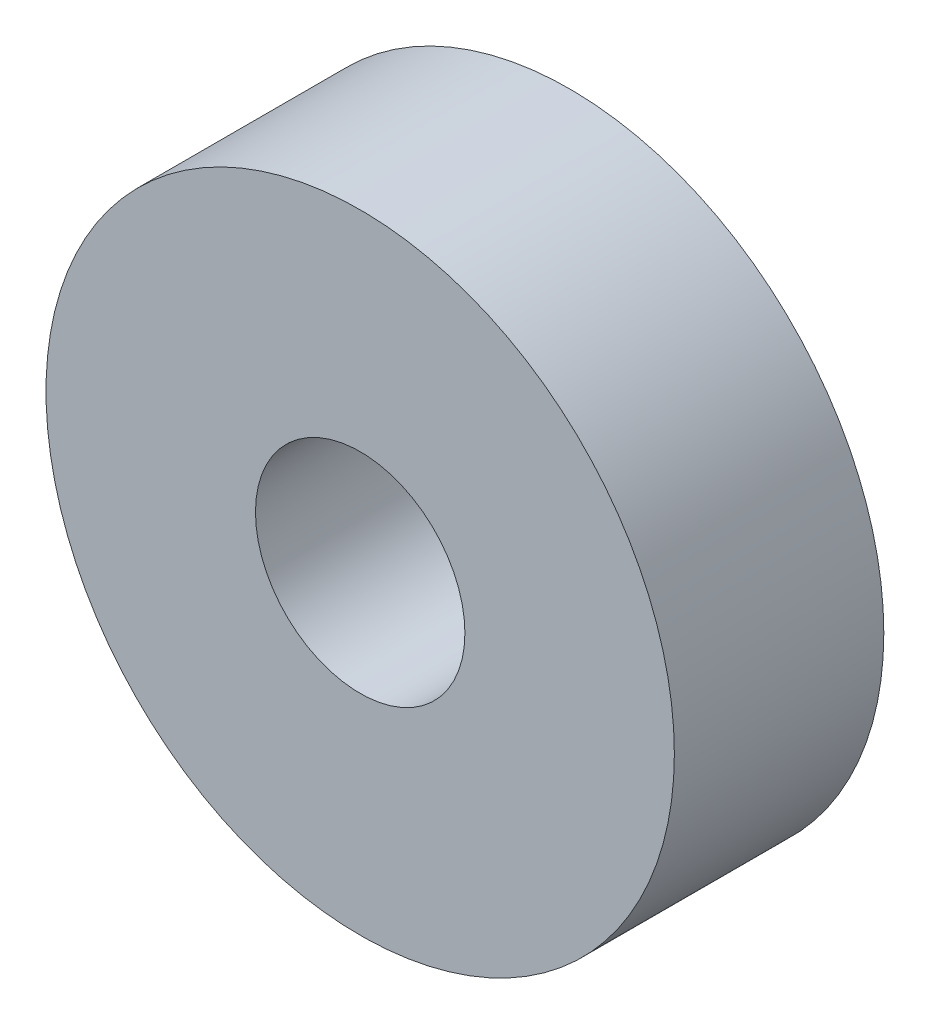
from build123d import *

# Parameters (mm, degrees)
SKETCH1_R           = 60
SKETCH1_R_2         = 20
BOSS_EXTRUDE1_DEPTH = 20


with BuildPart() as part:
    # Sketch1 → Boss-Extrude1 (new body, symmetric)
    with BuildSketch(Plane.XY):
        Circle(SKETCH1_R)
        Circle(SKETCH1_R_2, mode=Mode.SUBTRACT)
    extrude(amount=BOSS_EXTRUDE1_DEPTH, both=True)


solid = part.part
